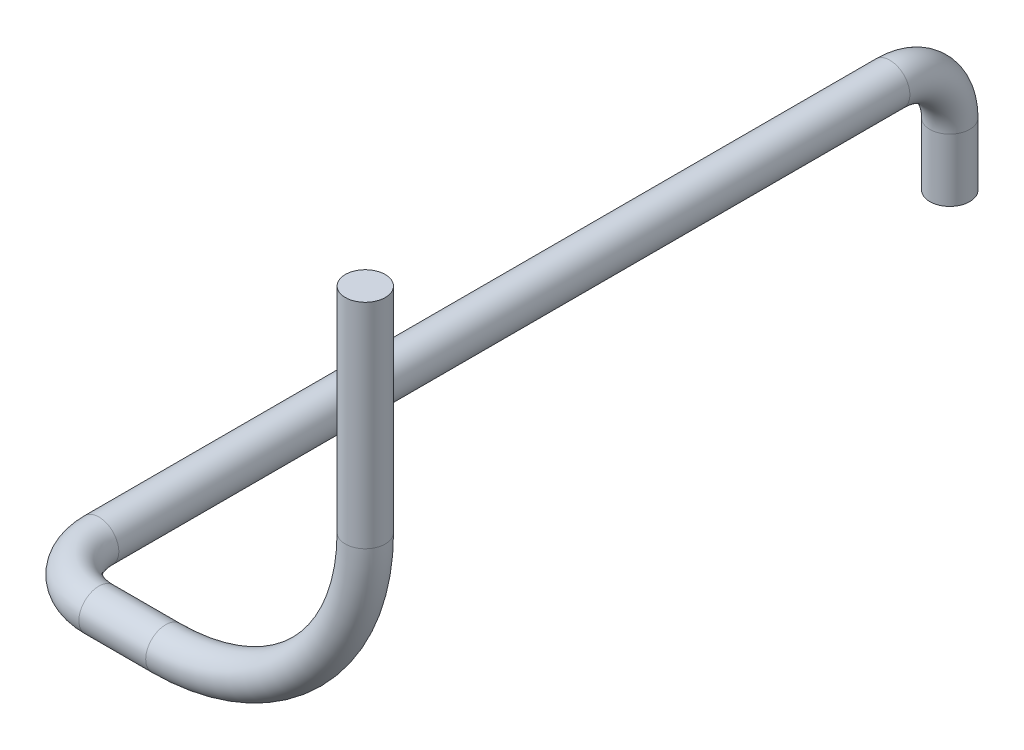
from build123d import *

# Parameters (mm, degrees)
SKETCH3_R = 1
SKETCH4_R = 1
SKETCH6_R = 1


with BuildPart() as part:
    # Sweep1: sweep along a path in Sketch1
    with BuildLine(Plane.XY) as sweep1_path:
        Line((0, 0), (0, -10.694484018))
        ThreePointArc((0, -10.694484018), (-2.928932188, -17.76555183), (-10, -20.694484018))
        Line((-10, -20.694484018), (-12.508437971, -20.694484018))
    # Sketch3 → Sweep1 (sweep)
    with BuildSketch(Plane(origin=(0, 0, 0), x_dir=(1, 0, 0), z_dir=(0, 1, 0))):
        Circle(SKETCH3_R)
    sweep(path=sweep1_path.line)

    # Sweep2: sweep along a path in Sketch2
    with BuildLine(Plane(origin=(0, -20.694484018, 0), x_dir=(1, 0, 0), z_dir=(0, 1, 0))) as sweep2_path:
        Line((-12.508437971, 0), (-13.348220683, 0))
        ThreePointArc((-13.348220683, 0), (-15.469541026, 0.878679656), (-16.348220683, 3))
        Line((-16.348220683, 3), (-16.348220683, 39.916632526))
    # Sketch4 → Sweep2 (sweep)
    with BuildSketch(Plane.ZY.offset(12.508437971)):
        with Locations((0, -20.694484018)):
            Circle(SKETCH4_R)
    sweep(path=sweep2_path.line)

    # Sweep3: sweep along a path in Sketch5
    with BuildLine(Plane(origin=(-16.348220683, 0, 0), x_dir=(0, 0, -1), z_dir=(1, 0, 0))) as sweep3_path:
        Line((39.916632526, -20.694484018), (42.629508897, -20.694484018))
        ThreePointArc((42.629508897, -20.694484018), (44.750829241, -21.573163675), (45.629508897, -23.694484018))
        Line((45.629508897, -23.694484018), (45.629508897, -26.831314156))
    # Sketch6 → Sweep3 (sweep)
    with BuildSketch(Plane(origin=(0, 0, -39.916632526), x_dir=(-1, 0, 0), z_dir=(0, 0, -1))):
        with Locations((16.348220683, -20.694484018)):
            Circle(SKETCH6_R)
    sweep(path=sweep3_path.line)


solid = part.part
